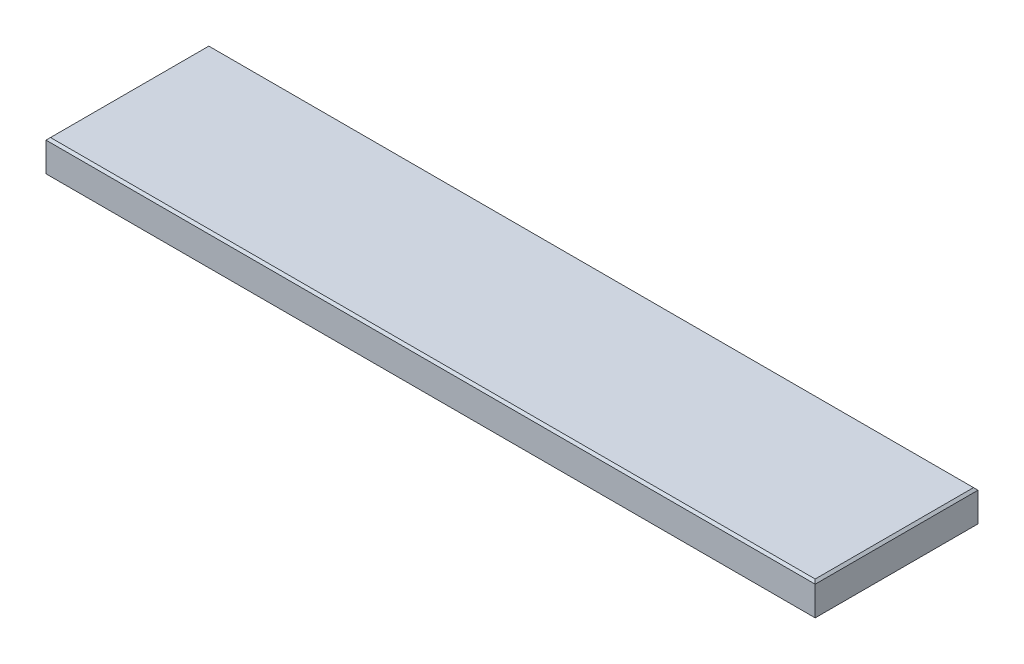
from build123d import *

# Parameters (mm, degrees)
SKETCH1_W           = 869.95
SKETCH1_H           = 184.15
BOSS_EXTRUDE1_DEPTH = 38.1
CHAMFER1_SIZE       = 2.54


with BuildPart() as part:
    # Sketch1 → Boss-Extrude1 (new body)
    with BuildSketch(Plane(origin=(0, 0, 0), x_dir=(1, 0, 0), z_dir=(0, 1, 0))):
        with Locations((434.975, 92.075)):
            Rectangle(SKETCH1_W, SKETCH1_H)
    extrude(amount=BOSS_EXTRUDE1_DEPTH)

    # Chamfer1
    chamfer1_edges = [part.edges().sort_by_distance(p)[0] for p in [
        (869.95, 38.1, -92.075),
        (434.975, 38.1, -184.15),
        (0, 38.1, -92.075),
        (434.975, 0, -184.15),
        (869.95, 0, -92.075),
        (434.975, 0, 0),
        (0, 0, -92.075),
        (434.975, 38.1, 0),
    ]]
    chamfer(chamfer1_edges, length=CHAMFER1_SIZE)


solid = part.part
